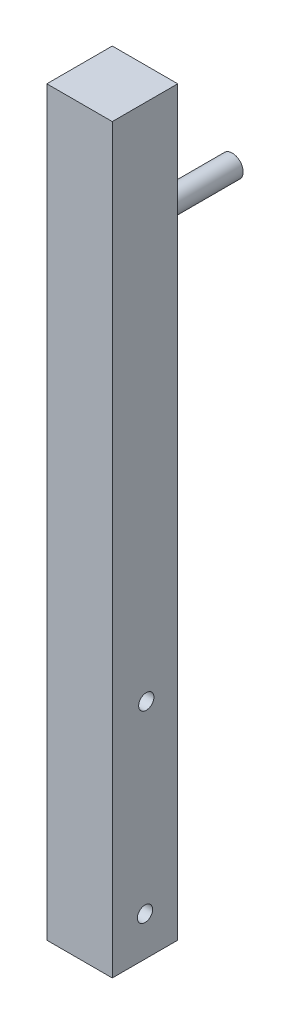
from build123d import *

# Parameters (mm, degrees)
SKETCH1_W           = 15
SKETCH1_H           = 15
BOSS_EXTRUDE1_DEPTH = 170
SKETCH2_R           = 1.75
CUT_EXTRUDE1_DEPTH  = 16
SKETCH3_R           = 4.05
CUT_EXTRUDE2_DEPTH  = 10
SKETCH5_R           = 2.5
BOSS_EXTRUDE3_DEPTH = 20


with BuildPart() as part:
    # Sketch1 → Boss-Extrude1 (new body)
    with BuildSketch(Plane(origin=(0, 0, 0), x_dir=(1, 0, 0), z_dir=(0, 1, 0))):
        Rectangle(SKETCH1_W, SKETCH1_H)
    extrude(amount=BOSS_EXTRUDE1_DEPTH)

    # Sketch2 → Cut-Extrude1 (cut, through all)
    with BuildSketch(Plane(origin=(7.5, 0, 0), x_dir=(0, 0, -1), z_dir=(1, 0, 0))):
        with Locations((0, 9)):
            Circle(SKETCH2_R)
        with Locations((0.295283966, 51)):
            Circle(SKETCH2_R)
    extrude(amount=-CUT_EXTRUDE1_DEPTH, mode=Mode.SUBTRACT)

    # Sketch3 → Cut-Extrude2 (cut)
    with BuildSketch(Plane.ZY.offset(7.5)):
        with Locations((0, 161)):
            Circle(SKETCH3_R)
        with Locations((0, 119)):
            Circle(SKETCH3_R)
    extrude(amount=-CUT_EXTRUDE2_DEPTH, mode=Mode.SUBTRACT)

    # Sketch5 → Boss-Extrude3 (add)
    with BuildSketch(Plane(origin=(0, 0, -7.5), x_dir=(-1, 0, 0), z_dir=(0, 0, -1))):
        with Locations((0, 140)):
            Circle(SKETCH5_R)
    extrude(amount=BOSS_EXTRUDE3_DEPTH)


solid = part.part
